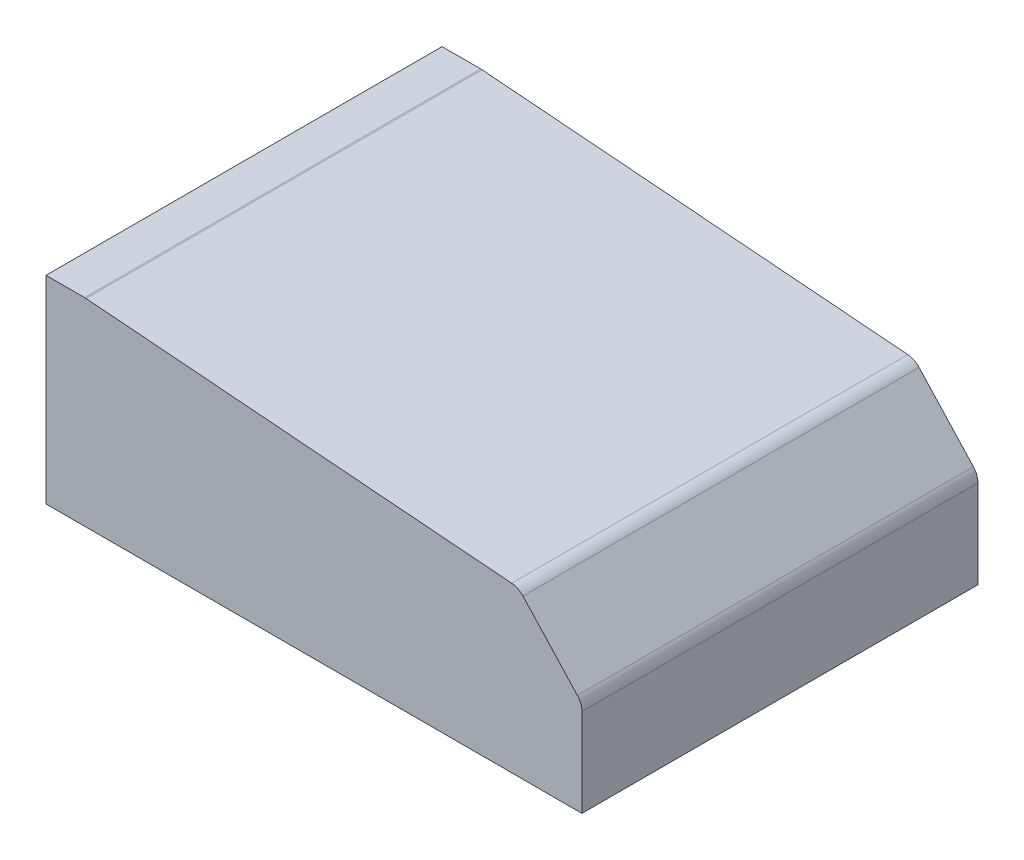
from build123d import *

# Parameters (mm, degrees)
BOSS_EXTRUDE1_DEPTH = 504
SHELL1_T            = -2


with BuildPart() as part:
    # Model → Boss-Extrude1 (new body)
    with BuildSketch(Plane.XY):
        with BuildLine():
            Line((0, 0), (0, 252))
            Line((0, 252), (49.207558746, 252))
            ThreePointArc((49.207558746, 252), (50.07856277, 251.982751238), (50.948201, 251.931032))
            Line((50.948201, 251.931032), (592.613138523, 208.939673232))
            ThreePointArc((592.613138523, 208.939673232), (600.483421158, 206.798288112), (607.032660761, 201.936771925))
            Line((607.032660761, 201.936771925), (676.160164376, 127.104105938))
            ThreePointArc((676.160164376, 127.104105938), (680.488089421, 120.190848365), (682, 112.1759752))
            Line((682, 112.1759752), (682, 0))
            Line((682, 0), (0, 0))
        make_face()
    extrude(amount=BOSS_EXTRUDE1_DEPTH)

    # Shell1
    shell1_openings = [part.faces().sort_by_distance(p)[0] for p in [
        (341, 0, 252),
        (0, 126, 252),
    ]]
    offset(amount=SHELL1_T, openings=shell1_openings, kind=Kind.INTERSECTION)


solid = part.part
